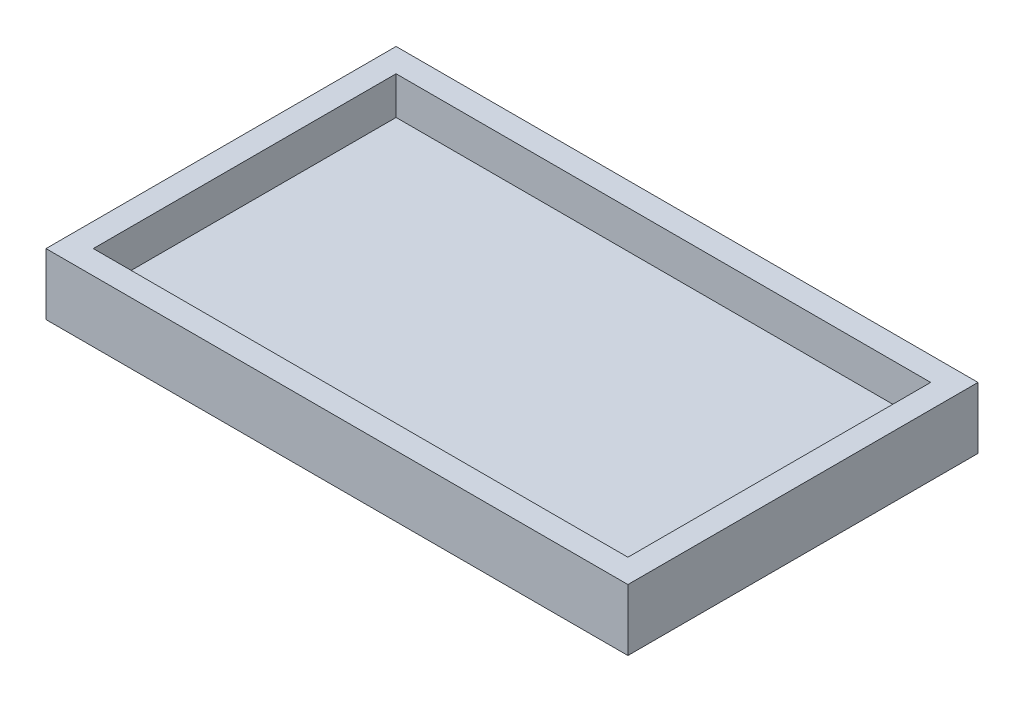
from build123d import *

# Parameters (mm, degrees)
SKETCH1_W           = 123
SKETCH1_H           = 74
BOSS_EXTRUDE1_DEPTH = 13
SKETCH3_W           = 113
SKETCH3_H           = 64
CUT_EXTRUDE1_DEPTH  = 8


with BuildPart() as part:
    # Sketch1 → Boss-Extrude1 (new body)
    with BuildSketch(Plane(origin=(0, 0, 0), x_dir=(1, 0, 0), z_dir=(0, 1, 0))):
        Rectangle(SKETCH1_W, SKETCH1_H)
    extrude(amount=BOSS_EXTRUDE1_DEPTH)

    # Sketch3 → Cut-Extrude1 (cut)
    with BuildSketch(Plane(origin=(0, 13, 0), x_dir=(1, 0, 0), z_dir=(0, 1, 0))):
        Rectangle(SKETCH3_W, SKETCH3_H)
    extrude(amount=-CUT_EXTRUDE1_DEPTH, mode=Mode.SUBTRACT)


solid = part.part
